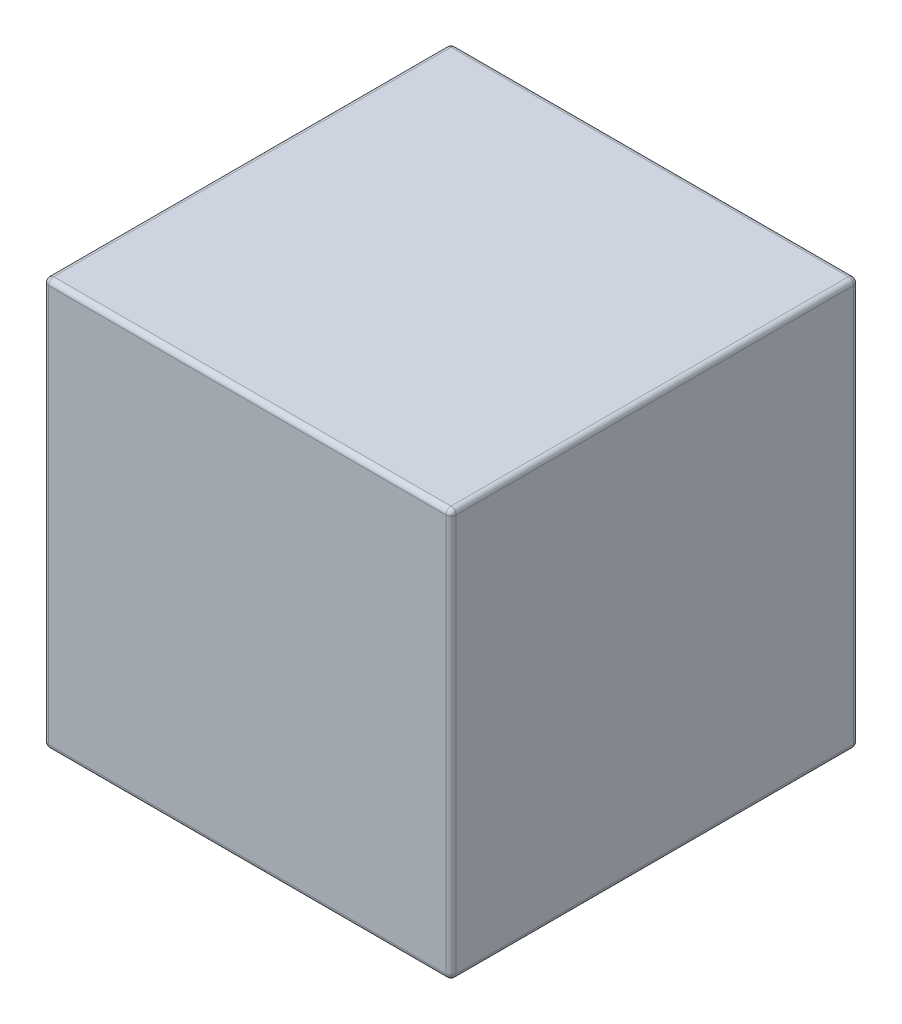
from build123d import *

# Parameters (mm, degrees)
SKETCH1_W           = 50.8
SKETCH1_H           = 50.8
BOSS_EXTRUDE1_DEPTH = 50.8
FILLET1_R           = 0.635


with BuildPart() as part:
    # Sketch1 → Boss-Extrude1 (new body)
    with BuildSketch(Plane(origin=(0, 0, 0), x_dir=(1, 0, 0), z_dir=(0, 1, 0))):
        Rectangle(SKETCH1_W, SKETCH1_H)
    extrude(amount=BOSS_EXTRUDE1_DEPTH)

    # Fillet1
    fillet1_edges = [part.edges().sort_by_distance(p)[0] for p in [
        (-25.4, 50.8, 0),
        (0, 50.8, 25.4),
        (25.4, 50.8, 0),
        (0, 0, 25.4),
        (-25.4, 0, 0),
        (0, 0, -25.4),
        (25.4, 0, 0),
        (25.4, 25.4, 25.4),
        (-25.4, 25.4, 25.4),
        (-25.4, 25.4, -25.4),
        (25.4, 25.4, -25.4),
        (0, 50.8, -25.4),
    ]]
    fillet(fillet1_edges, radius=FILLET1_R)


solid = part.part
